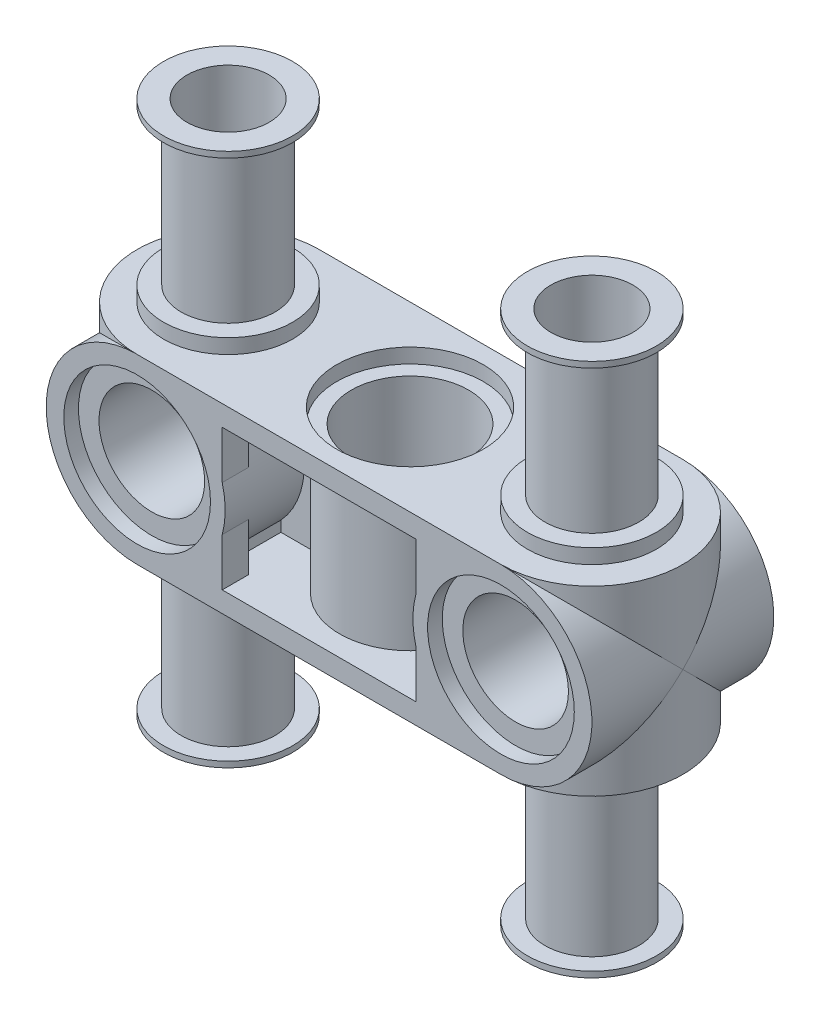
from build123d import *

# Parameters (mm, degrees)
EXTRUDE1_DEPTH     = 3.937
SKETCH2_R          = 2.794
CUT_EXTRUDE1_DEPTH = 0.254
SKETCH3_R          = 2.794
EXTRUDE2_DEPTH     = 0.635
SKETCH5_R          = 2.032
SKETCH5_R_2        = 1.778
EXTRUDE4_DEPTH     = 6.985
SKETCH6_R          = 2.794
SKETCH6_R_2        = 1.778
EXTRUDE5_DEPTH     = 0.254
EXTRUDE6_DEPTH     = 7.874
SKETCH8_R          = 2.54
CUT_EXTRUDE2_DEPTH = 3.556
SKETCH9_R          = 2.286
CUT_EXTRUDE3_DEPTH = 8.874
SKETCH10_R         = 3.175
CUT_EXTRUDE4_DEPTH = 0.635
CUT_EXTRUDE6_DEPTH = 3.048
SKETCH13_R         = 2.54
CUT_EXTRUDE7_DEPTH = 9.001
SKETCH14_R         = 3.175
CUT_EXTRUDE8_DEPTH = 0.635
EXTRUDE8_DEPTH     = 7.112


with BuildPart() as part:
    # Sketch1 → Extrude1 (new body)
    with BuildSketch(Plane(origin=(0, 0, 0), x_dir=(1, 0, 0), z_dir=(0, 1, 0))):
        with BuildLine():
            Line((-7.874, 3.937), (7.874, 3.937))
            ThreePointArc((7.874, 3.937), (11.811, 0), (7.874, -3.937))
            Line((7.874, -3.937), (-7.874, -3.937))
            ThreePointArc((-7.874, -3.937), (-11.811, 0), (-7.874, 3.937))
        make_face()
    extrude(amount=EXTRUDE1_DEPTH)

    # Sketch2 → Cut-Extrude1 (cut)
    with BuildSketch(Plane.XZ):
        Circle(SKETCH2_R)
    extrude(amount=-CUT_EXTRUDE1_DEPTH, mode=Mode.SUBTRACT)

    # Sketch3 → Extrude2 (add)
    with BuildSketch(Plane.XZ):
        with Locations((7.874, 0)):
            Circle(SKETCH3_R)
        with Locations((-7.874, 0)):
            Circle(SKETCH3_R)
    extrude(amount=EXTRUDE2_DEPTH)

    # Sketch5 → Extrude4 (add)
    with BuildSketch(Plane.XZ.offset(0.635)):
        with Locations((7.874, 0)):
            Circle(SKETCH5_R)
        with Locations((7.874, 0)):
            Circle(SKETCH5_R_2, mode=Mode.SUBTRACT)
        with Locations((-7.874, 0)):
            Circle(SKETCH5_R)
        with Locations((-7.874, 0)):
            Circle(SKETCH5_R_2, mode=Mode.SUBTRACT)
    extrude(amount=EXTRUDE4_DEPTH)

    # Sketch6 → Extrude5 (add)
    with BuildSketch(Plane.XZ.offset(7.62)):
        with Locations((-7.874, 0)):
            Circle(SKETCH6_R)
        with Locations((-7.874, 0)):
            Circle(SKETCH6_R_2, mode=Mode.SUBTRACT)
        with Locations((7.874, 0)):
            Circle(SKETCH6_R)
        with Locations((7.874, 0)):
            Circle(SKETCH6_R_2, mode=Mode.SUBTRACT)
    extrude(amount=-EXTRUDE5_DEPTH)

    # Sketch7 → Extrude6 (add)
    with BuildSketch(Plane(origin=(0, 0, -3.937), x_dir=(-1, 0, 0), z_dir=(0, 0, -1))):
        with BuildLine():
            Line((-7.874, 0), (7.874, 0))
            ThreePointArc((7.874, 0), (10.657879398, 1.153120602), (11.811, 3.937))
            Line((11.811, 3.937), (7.874, 3.937))
            Line((7.874, 3.937), (-7.874, 3.937))
            Line((-7.874, 3.937), (-11.811, 3.937))
            ThreePointArc((-11.811, 3.937), (-10.657879398, 1.153120602), (-7.874, 0))
        make_face()
    extrude(amount=-EXTRUDE6_DEPTH)

    # Sketch8 → Cut-Extrude2 (cut)
    with BuildSketch(Plane(origin=(0, 3.937, 0), x_dir=(1, 0, 0), z_dir=(0, 1, 0))):
        Circle(SKETCH8_R)
    extrude(amount=-CUT_EXTRUDE2_DEPTH, mode=Mode.SUBTRACT)

    # Sketch9 → Cut-Extrude3 (cut, through all)
    with BuildSketch(Plane.XY.offset(3.937)):
        with Locations((7.874, 3.937)):
            Circle(SKETCH9_R)
        with Locations((-7.874, 3.937)):
            Circle(SKETCH9_R)
    extrude(amount=-CUT_EXTRUDE3_DEPTH, mode=Mode.SUBTRACT)

    # Sketch10 → Cut-Extrude4 (cut)
    with BuildSketch(Plane.XY.offset(3.937)):
        with Locations((7.874, 3.937)):
            Circle(SKETCH10_R)
        with Locations((-7.874, 3.937)):
            Circle(SKETCH10_R)
    cut_extrude4 = extrude(amount=-CUT_EXTRUDE4_DEPTH, mode=Mode.SUBTRACT)

    # Mirror2: Cut-Extrude4 across plane
    add(cut_extrude4.mirror(Plane.XY), mode=Mode.SUBTRACT)

    # Sketch11 → Cut-Extrude6 (cut)
    with BuildSketch(Plane(origin=(0, 3.937, 0), x_dir=(1, 0, 0), z_dir=(0, 1, 0))):
        with BuildLine():
            Line((-5.08, -0.508), (-5.08, -2.794))
            Line((-5.08, -2.794), (-4.191, -2.794))
            Line((-4.191, -2.794), (-4.191, -3.937))
            Line((-4.191, -3.937), (4.191, -3.937))
            Line((4.191, -3.937), (4.191, -2.794))
            Line((4.191, -2.794), (5.08, -2.794))
            Line((5.08, -2.794), (5.08, -0.508))
            Line((5.08, -0.508), (3.00536853, -0.508))
            ThreePointArc((3.00536853, -0.508), (0, -3.048), (-3.00536853, -0.508))
            Line((-3.00536853, -0.508), (-5.08, -0.508))
        make_face()
        with BuildLine():
            Line((5.08, 0.508), (5.08, 2.794))
            Line((5.08, 2.794), (4.191, 2.794))
            Line((4.191, 2.794), (4.191, 3.937))
            Line((4.191, 3.937), (-4.191, 3.937))
            Line((-4.191, 3.937), (-4.191, 2.794))
            Line((-4.191, 2.794), (-5.08, 2.794))
            Line((-5.08, 2.794), (-5.08, 0.508))
            Line((-5.08, 0.508), (-3.00536853, 0.508))
            ThreePointArc((-3.00536853, 0.508), (0, 3.048), (3.00536853, 0.508))
            Line((3.00536853, 0.508), (5.08, 0.508))
        make_face()
    extrude(amount=-CUT_EXTRUDE6_DEPTH, mode=Mode.SUBTRACT)

    # Sketch13 → Cut-Extrude7 (cut, through all)
    with BuildSketch(Plane(origin=(0, 0.381, 0), x_dir=(1, 0, 0), z_dir=(0, 1, 0))):
        Circle(SKETCH13_R)
    extrude(amount=-CUT_EXTRUDE7_DEPTH, mode=Mode.SUBTRACT)

    # Sketch14 → Cut-Extrude8 (cut)
    with BuildSketch(Plane.XZ):
        Circle(SKETCH14_R)
    extrude(amount=-CUT_EXTRUDE8_DEPTH, mode=Mode.SUBTRACT)

    # Sketch17 → Extrude8 (add)
    with BuildSketch(Plane.XY.offset(3.937)):
        with BuildLine():
            Line((-4.064, 3.937), (-4.699, 3.937))
            ThreePointArc((-4.699, 3.937), (-7.874, 0.762), (-11.049, 3.937))
            Line((-11.049, 3.937), (-11.684, 3.937))
            ThreePointArc((-11.684, 3.937), (-7.874, 0.127), (-4.064, 3.937))
        make_face()
    extrude8 = extrude(amount=-EXTRUDE8_DEPTH)

    # Mirror3: Extrude8 across plane
    add(extrude8.mirror(Plane(origin=(0, 0, 0), x_dir=(0, 0, 1), z_dir=(1, 0, 0))))

    # Mirror1: part across face


with BuildPart() as part_1:
    add(part.part)
    add(part.part.mirror(Plane(origin=(0, 3.937, 0.023671087), x_dir=(0, 0, 1), z_dir=(0, 1, 0))))


solid = part_1.part
